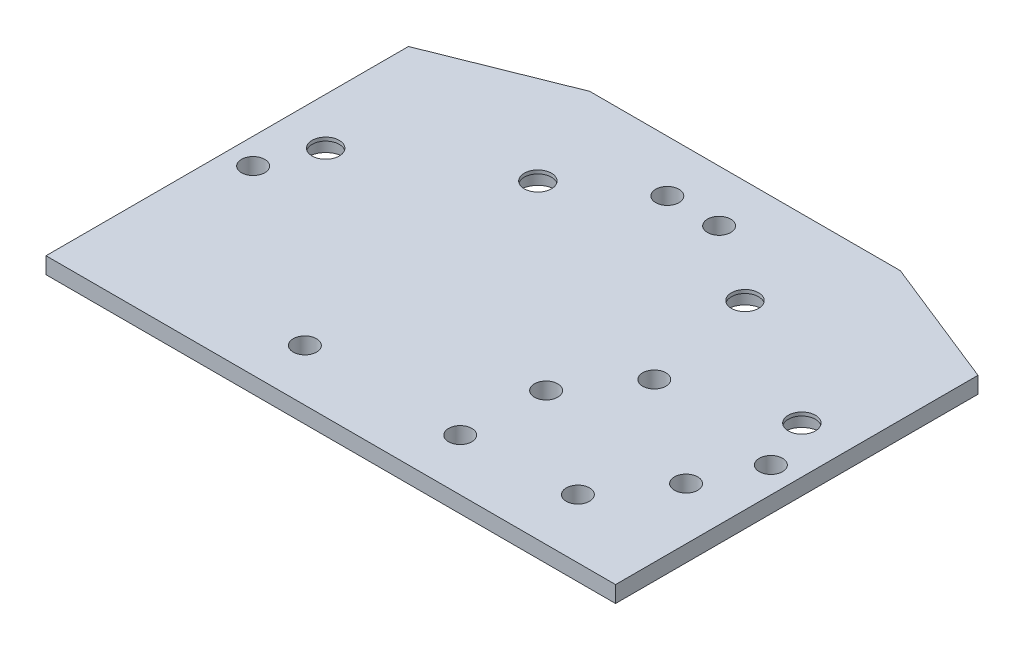
from build123d import *

# Parameters (mm, degrees)
BOSS_EXTRUDE1_DEPTH   = 1.5875
F_1_0MM_DOWEL_HOLE1_D = 5.25
SKETCH6_R             = 3.45
CUT_EXTRUDE2_DEPTH    = 2.5
M4_CLEARANCE_HOLE1_D  = 4.5
M4_CLEARANCE_HOLE2_D  = 4.5
M4_CLEARANCE_HOLE3_D  = 4.5
M4_CLEARANCE_HOLE4_D  = 4.5


with BuildPart() as part:
    # Sketch1 → Boss-Extrude1 (new body, symmetric)
    with BuildSketch(Plane(origin=(0, 0, 0), x_dir=(1, 0, 0), z_dir=(0, 1, 0))):
        Polygon((-55, 15), (-30, 25), (30, 25), (55, 15), (55, -55), (-55, -55), align=None)
    extrude(amount=BOSS_EXTRUDE1_DEPTH, both=True)

    # Ø1.0mm Dowel Hole1 (through all)
    with Locations(Plane(origin=(0, 1.5875, 0), x_dir=(1, 0, 0), z_dir=(0, 1, 0))):
        with Locations((-20, 5), (20, 5), (45.980762114, -10), (-45.980762114, -10)):
            Hole(F_1_0MM_DOWEL_HOLE1_D / 2)

    # Sketch6 → Cut-Extrude2 (cut)
    with BuildSketch(Plane.XZ.offset(1.5875)):
        with Locations((-45.980762114, 10)):
            Circle(SKETCH6_R)
        with Locations((-20, -5)):
            Circle(SKETCH6_R)
        with Locations((20, -5)):
            Circle(SKETCH6_R)
        with Locations((45.980762114, 10)):
            Circle(SKETCH6_R)
    extrude(amount=-CUT_EXTRUDE2_DEPTH, mode=Mode.SUBTRACT)

    # M4 Clearance Hole1 (through all)
    with Locations(Plane(origin=(0, -1.5875, 0), x_dir=(-1, 0, 0), z_dir=(0, -1, 0))):
        with Locations((-24.440273443, -16.961605049), (-15.836626898, -29.248885713), (-44.91907455, -31.301015958), (-36.315428005, -43.588296622)):
            Hole(M4_CLEARANCE_HOLE1_D / 2)

    # M4 Clearance Hole2 (through all)
    with Locations(Plane(origin=(0, -1.5875, 0), x_dir=(-1, 0, 0), z_dir=(0, -1, 0))):
        with Locations((-5, 15), (5, 15)):
            Hole(M4_CLEARANCE_HOLE2_D / 2)

    # M4 Clearance Hole3 (through all)
    with Locations(Plane(origin=(0, 1.5875, 0), x_dir=(1, 0, 0), z_dir=(0, 1, 0))):
        with Locations((-15, -45), (15, -45)):
            Hole(M4_CLEARANCE_HOLE3_D / 2)

    # M4 Clearance Hole4 (through all)
    with Locations(Plane(origin=(0, 1.5875, 0), x_dir=(1, 0, 0), z_dir=(0, 1, 0))):
        with Locations((50, -20), (-50, -20)):
            Hole(M4_CLEARANCE_HOLE4_D / 2)


solid = part.part
